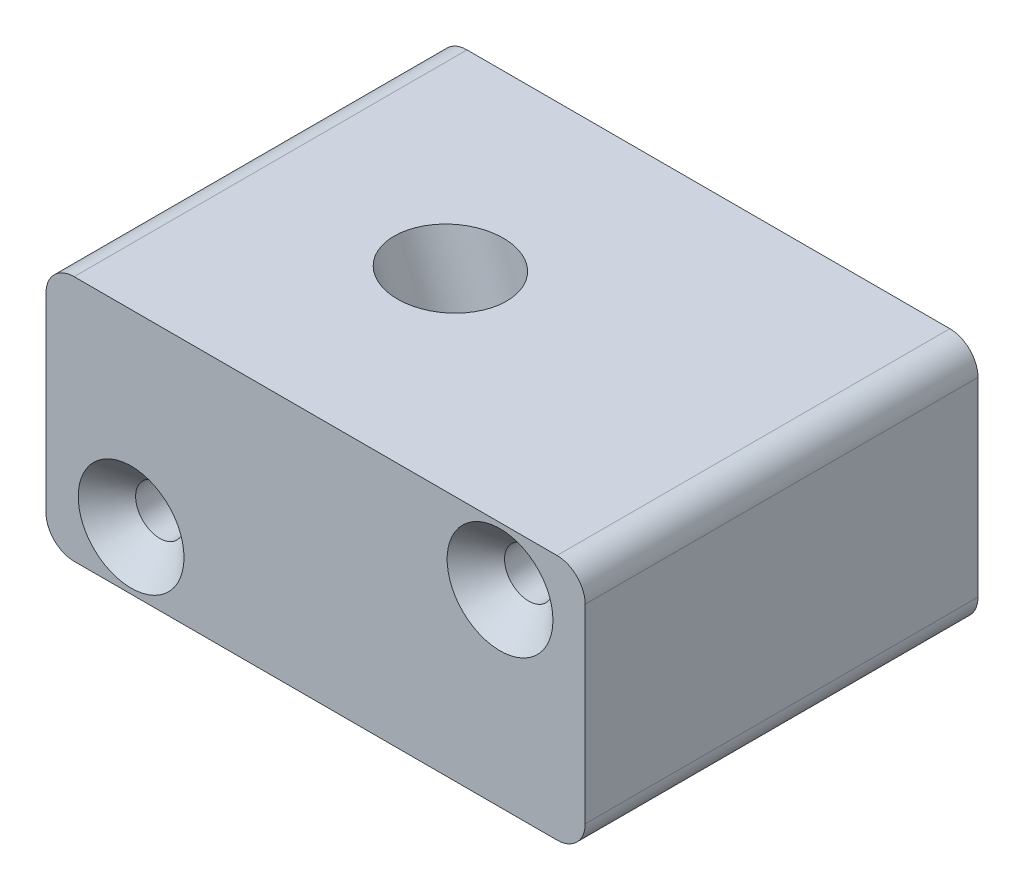
from build123d import *

# Parameters (mm, degrees)
BOSS_EXTRUDE1_DEPTH                             = 17.45
CSK_FOR_M4_FLAT_HEAD_MACHINE_SCREW1_D           = 4.3
CSK_FOR_M4_FLAT_HEAD_MACHINE_SCREW1_CSINK_D     = 9.4
CSK_FOR_M4_FLAT_HEAD_MACHINE_SCREW1_CSINK_ANGLE = 90
SKETCH24_W                                      = 4.699
SKETCH24_H                                      = 41.40401941


with BuildPart() as part:
    # Sketch1 → Boss-Extrude1 (new body, symmetric)
    with BuildSketch(Plane.XY):
        with BuildLine():
            Line((-21.45, -10.95), (21.45, -10.95))
            ThreePointArc((21.45, -10.95), (23.217766953, -10.217766953), (23.95, -8.45))
            Line((23.95, -8.45), (23.95, 8.45))
            ThreePointArc((23.95, 8.45), (23.217766953, 10.217766953), (21.45, 10.95))
            Line((21.45, 10.95), (-21.45, 10.95))
            ThreePointArc((-21.45, 10.95), (-23.217766953, 10.217766953), (-23.95, 8.45))
            Line((-23.95, 8.45), (-23.95, -8.45))
            ThreePointArc((-23.95, -8.45), (-23.217766953, -10.217766953), (-21.45, -10.95))
        make_face()
    extrude(amount=BOSS_EXTRUDE1_DEPTH, both=True)

    # CSK for M4 Flat Head Machine Screw1 (through all)
    with Locations(Plane.XY.offset(17.45)):
        with Locations((-16.388274302, -5.782084253), (16.388274302, 5.782084253)):
            CounterSinkHole(CSK_FOR_M4_FLAT_HEAD_MACHINE_SCREW1_D / 2, CSK_FOR_M4_FLAT_HEAD_MACHINE_SCREW1_CSINK_D / 2, counter_sink_angle=CSK_FOR_M4_FLAT_HEAD_MACHINE_SCREW1_CSINK_ANGLE)

    # Sketch24 → Hosel Diameter (revolve, cut)
    with BuildSketch(Plane(origin=(-1.212269458, -0.441229999, 0), x_dir=(0, 0, -1), z_dir=(0.939692621, 0.342020143, 0))):
        with Locations((2.2345, -1.146750947)):
            Rectangle(SKETCH24_W, SKETCH24_H)
    revolve(axis=Axis((-7.900561861, 17.934702354, 0.115), (0.342020143, -0.939692621, 0)), mode=Mode.SUBTRACT)


solid = part.part
